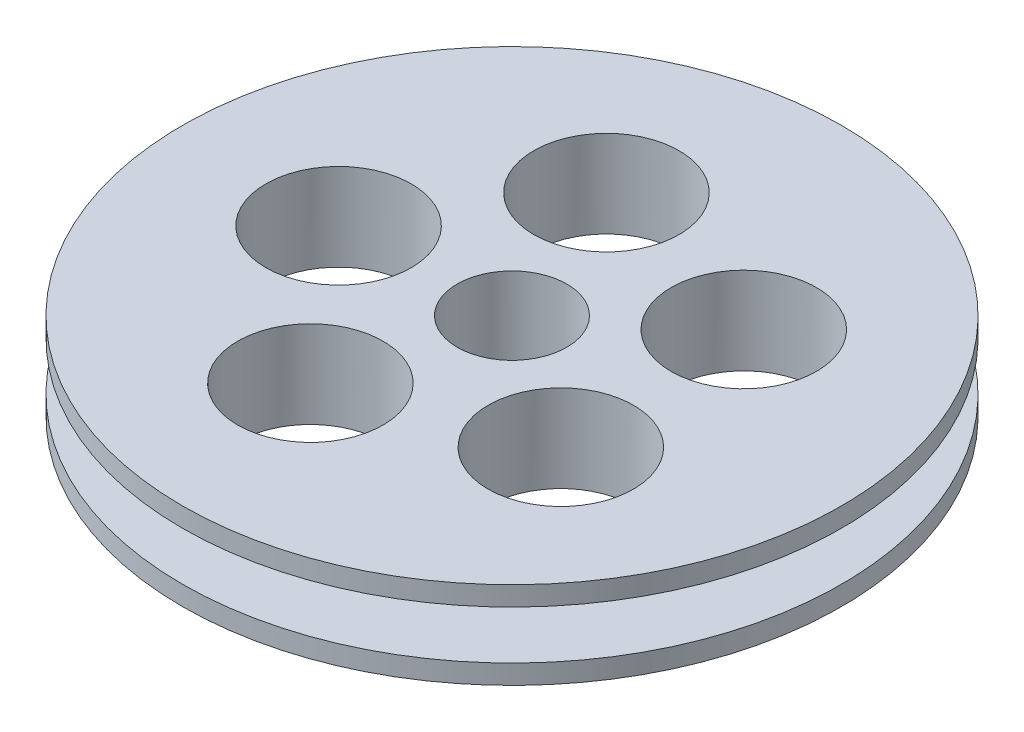
from build123d import *

# Parameters (mm, degrees)
SKETCH1_W          = 22
SKETCH1_H          = 5
SKETCH1_W_2        = 30
SKETCH1_H_2        = 2
SKETCH3_R          = 5.653749864
SKETCH3_R_2        = 7.5
CUT_EXTRUDE1_DEPTH = 10


with BuildPart() as part:
    # Sketch1 → Revolve4 (revolve)
    with BuildSketch(Plane(origin=(0, 0, 0), x_dir=(0, 0, -1), z_dir=(1, 0, 0))):
        Polygon((0, 7), (0, 5), (22, 5), (30, 5), (30, 7), align=None)
        with Locations((11, 2.5)):
            Rectangle(SKETCH1_W, SKETCH1_H)
        with Locations((15, -1)):
            Rectangle(SKETCH1_W_2, SKETCH1_H_2)
    revolve(axis=Axis((0, 2.5, 4), (0, 1, 0)))

    # Sketch3 → Cut-Extrude1 (cut)
    with BuildSketch(Plane(origin=(0, 7, 0), x_dir=(1, 0, 0), z_dir=(0, 1, 0))):
        with Locations((0, -4)):
            Circle(SKETCH3_R)
        with Locations((-16.975218646, -4.917579386)):
            Circle(SKETCH3_R_2)
        with Locations((-6.118300899, 11.860844685)):
            Circle(SKETCH3_R_2)
        with Locations((13.193900737, 6.720120492)):
            Circle(SKETCH3_R_2)
        with Locations((14.272579999, -13.235445857)):
            Circle(SKETCH3_R_2)
        with Locations((-4.37296119, -20.427939933)):
            Circle(SKETCH3_R_2)
    extrude(amount=-CUT_EXTRUDE1_DEPTH, mode=Mode.SUBTRACT)


solid = part.part
